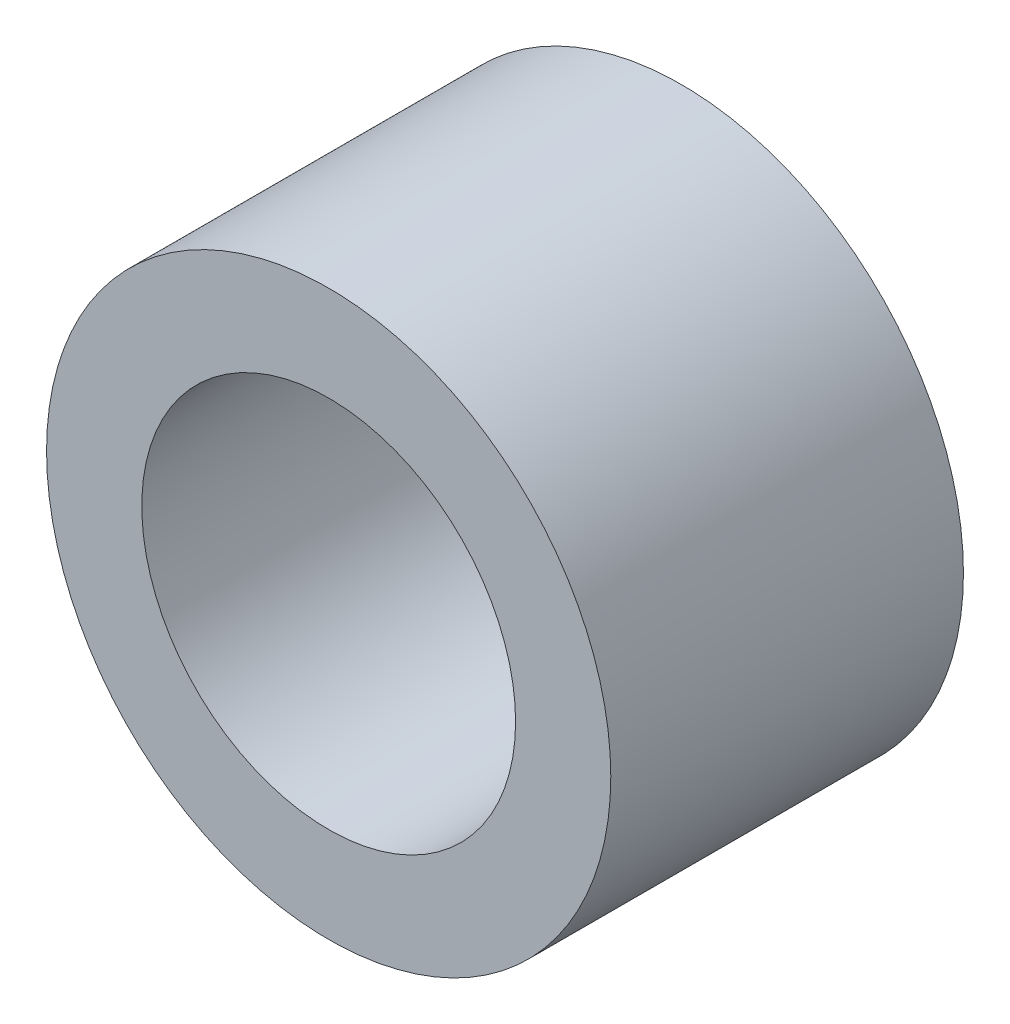
from build123d import *

# Parameters (mm, degrees)
SKETCH1_R           = 4
SKETCH1_R_2         = 2.65
EXTRUDE1_DEPTH      = 2.5
EXTRUDE1_DEPTH_BACK = 2.5


with BuildPart() as part:
    # Sketch1 → Extrude1 (new body, two sides)
    with BuildSketch(Plane.XY) as extrude1_sk:
        Circle(SKETCH1_R)
        Circle(SKETCH1_R_2, mode=Mode.SUBTRACT)
    extrude(amount=EXTRUDE1_DEPTH)
    extrude(extrude1_sk.sketch, amount=-EXTRUDE1_DEPTH_BACK)


solid = part.part
